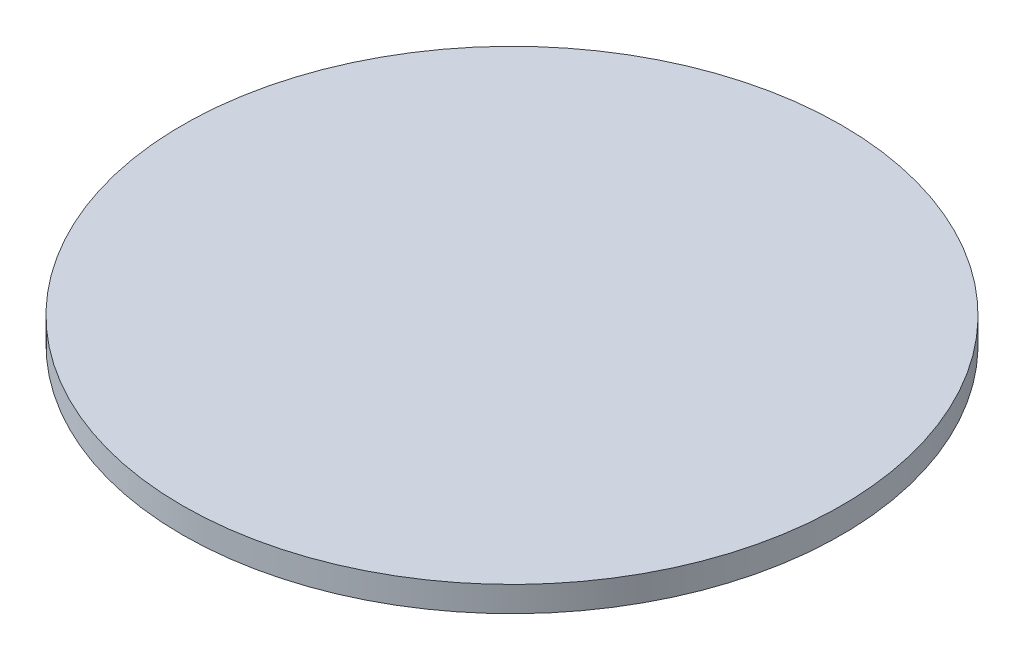
from build123d import *

# Parameters (mm, degrees)
SKETCH1_R           = 82.55
BOSS_EXTRUDE1_DEPTH = 6.35


with BuildPart() as part:
    # Sketch1 → Boss-Extrude1 (new body)
    with BuildSketch(Plane(origin=(0, 0, 0), x_dir=(1, 0, 0), z_dir=(0, 1, 0))):
        Circle(SKETCH1_R)
    extrude(amount=BOSS_EXTRUDE1_DEPTH)


solid = part.part
